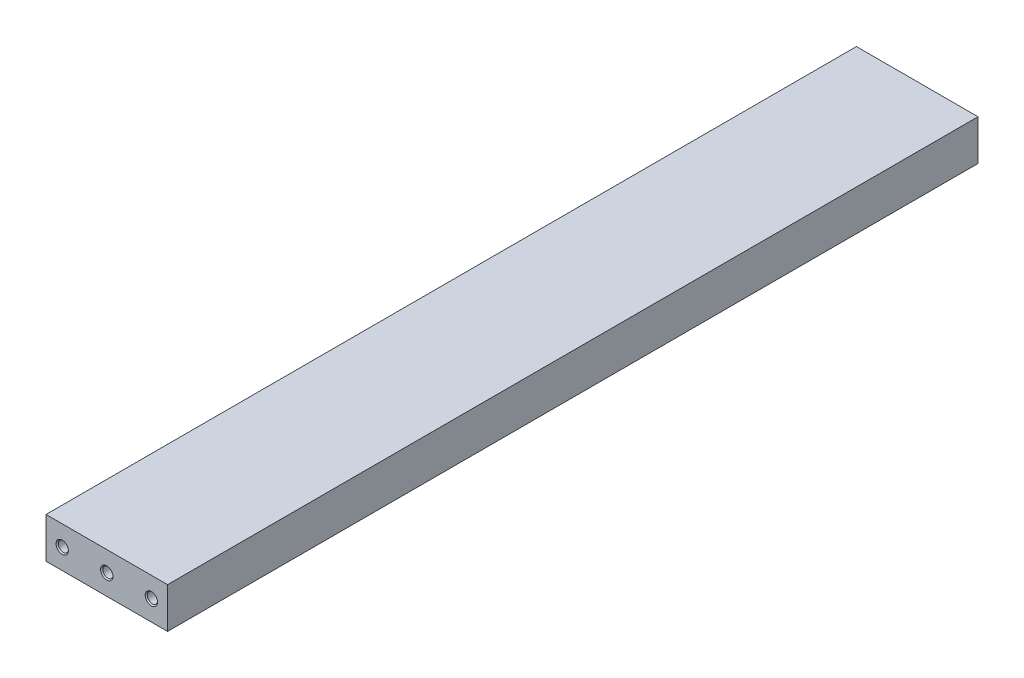
from build123d import *

# Parameters (mm, degrees)
SKETCH1_W                  = 30
SKETCH1_H                  = 10
BOSS_EXTRUDE1_DEPTH        = 210
SKETCH3_W                  = 30
SKETCH3_H                  = 5
CUT_EXTRUDE3_DEPTH         = 10
M3_TAPPED_HOLE1_AT_2_COUNT = 2
M3_TAPPED_HOLE1_AT_2_PITCH = 11
M3_TAPPED_HOLE1_AT_3_COUNT = 2
M3_TAPPED_HOLE1_AT_3_PITCH = 22


with BuildPart() as part:
    # Sketch1 → Boss-Extrude1 (new body)
    with BuildSketch(Plane.XY):
        with Locations((15, 5)):
            Rectangle(SKETCH1_W, SKETCH1_H)
    extrude(amount=BOSS_EXTRUDE1_DEPTH)

    # Sketch3 → Cut-Extrude3 (cut)
    with BuildSketch(Plane(origin=(0, 10, 0), x_dir=(1, 0, 0), z_dir=(0, 1, 0))):
        with Locations((15, -207.5)):
            Rectangle(SKETCH3_W, SKETCH3_H)
    cut_extrude3 = extrude(amount=-CUT_EXTRUDE3_DEPTH, mode=Mode.SUBTRACT)

    # Mirror2: Cut-Extrude3 across plane
    add(cut_extrude3.mirror(Plane(origin=(0, 0, 105), x_dir=(1, 0, 0), z_dir=(0, 0, -1))), mode=Mode.SUBTRACT)

    # Sketch6 → M3 Tapped Hole1 (revolve, cut)
    with BuildSketch(Plane(origin=(4, 5, 205), x_dir=(0, -1, 0), z_dir=(1, 0, 0))):
        Polygon((0, 0), (0, 9.251075774), (1.25, 8.5), (1.25, 0.275), (1.525, 0), align=None)
    m3_tapped_hole1 = revolve(axis=Axis((4, 5, 211.35), (0, 0, -1)), mode=Mode.SUBTRACT)

    # M3 Tapped Hole1 at 2: M3 Tapped Hole1 ×2
    with Locations(*[(i * M3_TAPPED_HOLE1_AT_2_PITCH, 0, 0) for i in range(1, M3_TAPPED_HOLE1_AT_2_COUNT)]):
        add(m3_tapped_hole1, mode=Mode.SUBTRACT)

    # M3 Tapped Hole1 at 3: M3 Tapped Hole1 ×2
    with Locations(*[(i * M3_TAPPED_HOLE1_AT_3_PITCH, 0, 0) for i in range(1, M3_TAPPED_HOLE1_AT_3_COUNT)]):
        add(m3_tapped_hole1, mode=Mode.SUBTRACT)

    # Mirror3: M3 Tapped Hole1 across plane
    add(m3_tapped_hole1.mirror(Plane.XY.offset(105)), mode=Mode.SUBTRACT)

    # Mirror3 copy 1 sketch → Mirror3 copy 1 (revolve, cut)
    with BuildSketch(Plane(origin=(15, 5, 5), x_dir=(0, -1, 0), z_dir=(1, 0, 0))):
        Polygon((0, 0), (0, -9.251075774), (1.25, -8.5), (1.25, -0.275), (1.525, 0), align=None)
    revolve(axis=Axis((15, 5, -1.35), (0, 0, -1)), mode=Mode.SUBTRACT)

    # Mirror3 copy 2 sketch → Mirror3 copy 2 (revolve, cut)
    with BuildSketch(Plane(origin=(26, 5, 5), x_dir=(0, -1, 0), z_dir=(1, 0, 0))):
        Polygon((0, 0), (0, -9.251075774), (1.25, -8.5), (1.25, -0.275), (1.525, 0), align=None)
    revolve(axis=Axis((26, 5, -1.35), (0, 0, -1)), mode=Mode.SUBTRACT)


solid = part.part
